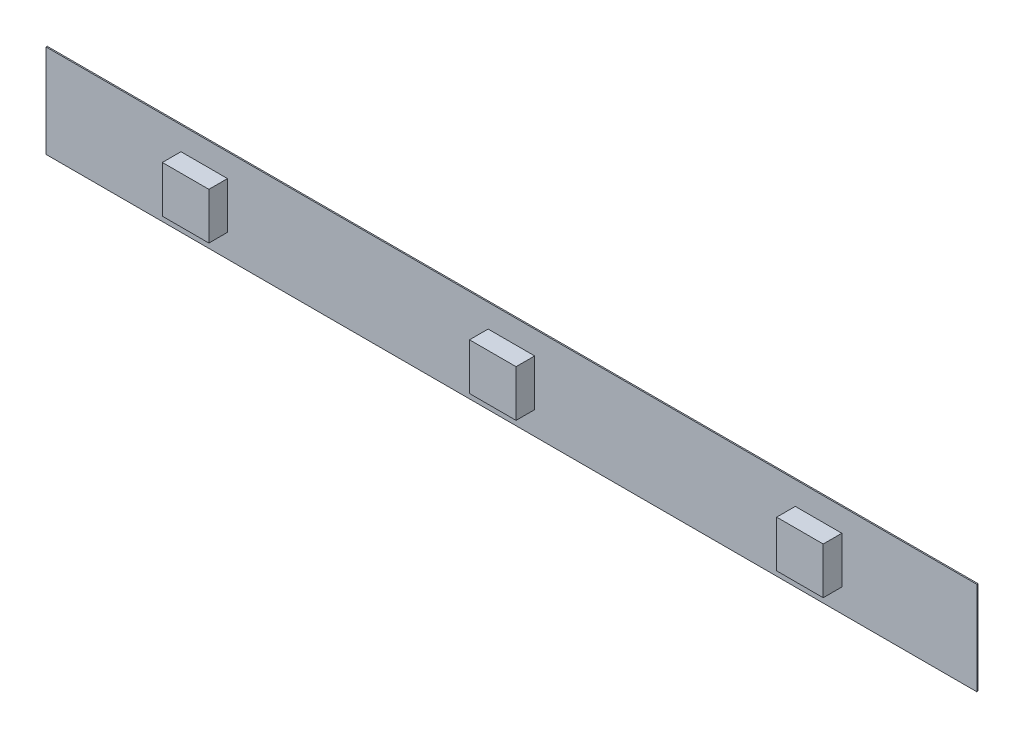
from build123d import *

# Parameters (mm, degrees)
CROQUIS1_W              = 100
CROQUIS1_H              = 10
SALIENTE_EXTRUIR1_DEPTH = 0.13
CROQUIS2_W              = 5
CROQUIS2_H              = 5
SALIENTE_EXTRUIR2_DEPTH = 2


with BuildPart() as part:
    # Croquis1 → Saliente-Extruir1 (new body)
    with BuildSketch(Plane.XY):
        with Locations((-4.415504013, 0.809859155)):
            Rectangle(CROQUIS1_W, CROQUIS1_H)
    extrude(amount=SALIENTE_EXTRUIR1_DEPTH)

    # Croquis2 → Saliente-Extruir2 (add)
    with BuildSketch(Plane.XY.offset(0.13)):
        with Locations((-37.415504013, 0.809859155)):
            Rectangle(CROQUIS2_W, CROQUIS2_H)
        with Locations((-4.415504013, 0.809859155)):
            Rectangle(CROQUIS2_W, CROQUIS2_H)
        with Locations((28.584495987, 0.809859155)):
            Rectangle(CROQUIS2_W, CROQUIS2_H)
    extrude(amount=SALIENTE_EXTRUIR2_DEPTH)


solid = part.part
